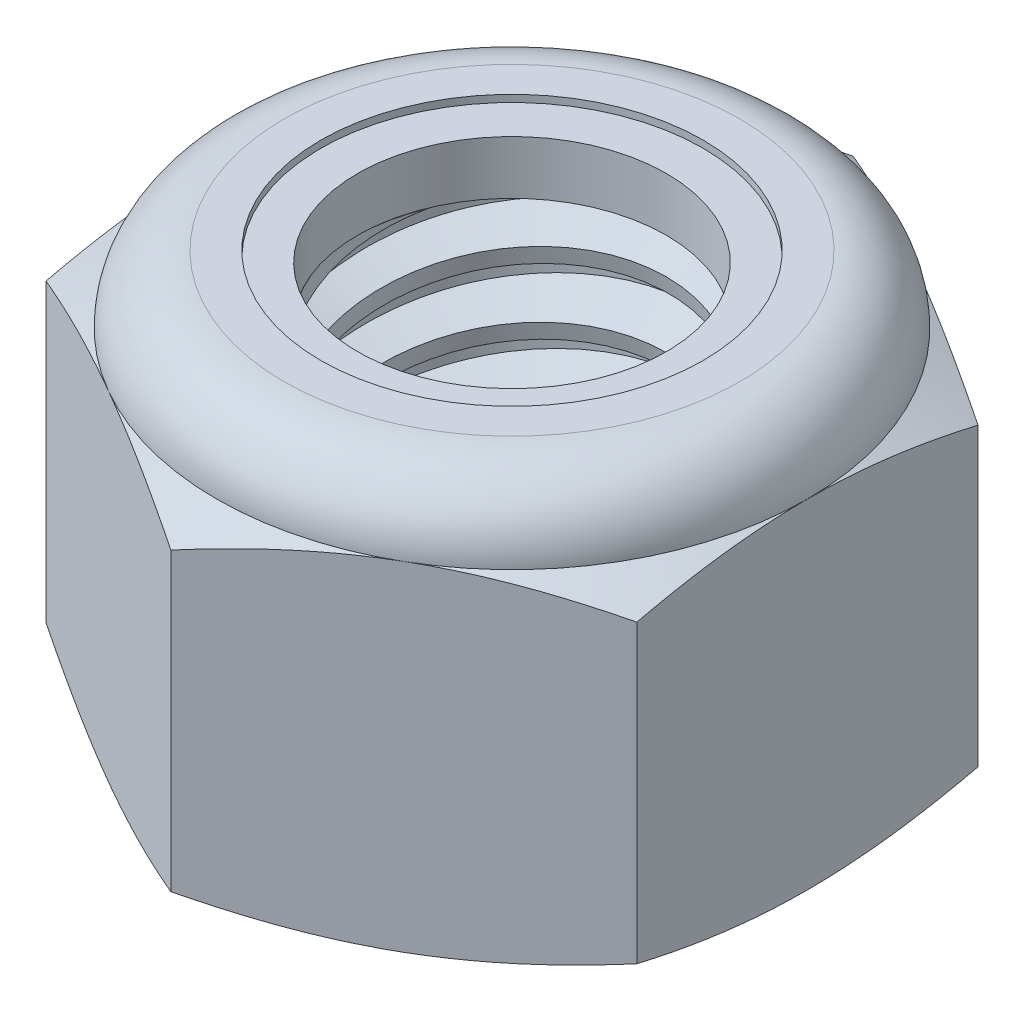
from build123d import *

# Parameters (mm, degrees)
EXTRUDE1_DEPTH       = 8.73125
SKETCH2_W            = 3.9624
SKETCH2_H            = 8.73125
LPATTERN1_COUNT      = 6
LPATTERN1_PITCH      = 1.411111111
LPATTERN1_COUNT_DIR2 = 2
LPATTERN1_PITCH_DIR2 = 1.411111111


with BuildPart() as part:
    # Sketch1 → Extrude1 (new body)
    with BuildSketch(Plane(origin=(0, 0, 0), x_dir=(1, 0, 0), z_dir=(0, 1, 0))):
        Polygon((0, 7.332348419), (-6.35, 3.666174209), (-6.35, -3.666174209), (0, -7.332348419), (6.35, -3.666174209), (6.35, 3.666174209), align=None)
    extrude(amount=EXTRUDE1_DEPTH)

    # Sketch4 → Cut-Revolve2 (revolve, cut)
    with BuildSketch(Plane(origin=(0, 0, 0), x_dir=(0, 0, -1), z_dir=(1, 0, 0))):
        Polygon((0, 8.73125), (3.9624, 8.73125), (3.318668226, 8.431072944), (3.318668226, 0.300177056), (3.9624, 0), (0, 0), align=None)
    revolve(axis=Axis((0, 8.73125, 0), (0, 1, 0)), mode=Mode.SUBTRACT)


with BuildPart() as body_2:
    # Sketch2 → Revolve1 (revolve)
    with BuildSketch(Plane(origin=(0, 0, 0), x_dir=(0, 0, -1), z_dir=(1, 0, 0))):
        with Locations((1.9812, 4.365625)):
            Rectangle(SKETCH2_W, SKETCH2_H)
    revolve(axis=Axis((0, -3.9624, 0), (0, 1, 0)))

    # Sketch3 → Cut-Revolve1 (revolve, cut)
    with BuildSketch(Plane(origin=(0, 0, 0), x_dir=(0, 0, -1), z_dir=(1, 0, 0))):
        Polygon((3.993321894, 8.557592646), (4.209775148, 7.341991167), (3.380512014, 7.642238826), (3.318668226, 7.989553534), align=None)
    cut_revolve1 = revolve(axis=Axis((0, 8.73125, 0.26919352), (0, -0.9845141333311523, -0.17530522317150174)), mode=Mode.SUBTRACT)

    # LPattern1: Cut-Revolve1 6 × 2
    with Locations(*[Vector(0, -1, 0) * (i * LPATTERN1_PITCH) + Vector(0, 1, 0) * (j * LPATTERN1_PITCH_DIR2) for i in range(LPATTERN1_COUNT) for j in range(LPATTERN1_COUNT_DIR2) if (i, j) != (0, 0)]):
        add(cut_revolve1, mode=Mode.SUBTRACT)


with BuildPart() as part_1:
    add(part.part)

    # Combine1: cut body 2
    add(body_2.part, mode=Mode.SUBTRACT)

    # Sketch5 → Cut-Revolve3 (revolve, cut)
    with BuildSketch(Plane(origin=(0, 0, 0), x_dir=(0, 0, -1), z_dir=(1, 0, 0))):
        with BuildLine():
            Line((0, 0), (6.35, 0))
            Line((6.35, 0), (7.332348419, 0.458076591))
            Line((7.332348419, 0.458076591), (7.332348419, 6.817965076))
            Line((7.332348419, 6.817965076), (6.35, 7.276041667))
            ThreePointArc((6.35, 7.276041667), (5.923779347, 8.305029347), (4.894791667, 8.73125))
            Line((4.894791667, 8.73125), (4.894791667, 10.00125))
            Line((4.894791667, 10.00125), (8.602348419, 10.00125))
            Line((8.602348419, 10.00125), (8.602348419, -1.27))
            Line((8.602348419, -1.27), (0, -1.27))
            Line((0, -1.27), (0, 0))
        make_face()
    revolve(axis=Axis((0, 0, 0), (0, 1, 0)), mode=Mode.SUBTRACT)

    # Sketch6 → Cut-Revolve4 (revolve, cut)
    with BuildSketch(Plane(origin=(0, 0, 0), x_dir=(0, 0, -1), z_dir=(1, 0, 0))):
        with BuildLine():
            Line((0, 7.276041667), (6.1976, 7.276041667))
            ThreePointArc((6.1976, 7.276041667), (5.816016274, 8.197266274), (4.894791667, 8.57885))
            Line((4.894791667, 8.57885), (4.106729947, 8.57885))
            Line((4.106729947, 8.57885), (4.106729947, 10.00125))
            Line((4.106729947, 10.00125), (0, 10.00125))
            Line((0, 10.00125), (0, 7.276041667))
        make_face()
    revolve(axis=Axis((0, 10.00125, 0), (0, 1, 0)), mode=Mode.SUBTRACT)


with BuildPart() as body_2_2:
    # Sketch7 → Revolve2 (revolve)
    with BuildSketch(Plane(origin=(0, 0, 0), x_dir=(0, 0, -1), z_dir=(1, 0, 0))):
        with BuildLine():
            Line((3.318668226, 7.352241667), (6.119030844, 7.352241667))
            ThreePointArc((6.119030844, 7.352241667), (5.734762038, 8.169919611), (4.894791667, 8.50265))
            Line((4.894791667, 8.50265), (3.318668226, 8.50265))
            Line((3.318668226, 8.50265), (3.318668226, 7.352241667))
        make_face()
    revolve(axis=Axis((0, 7.352241667, 0), (0, 1, 0)))


solid = Compound([part_1.part, body_2_2.part])
